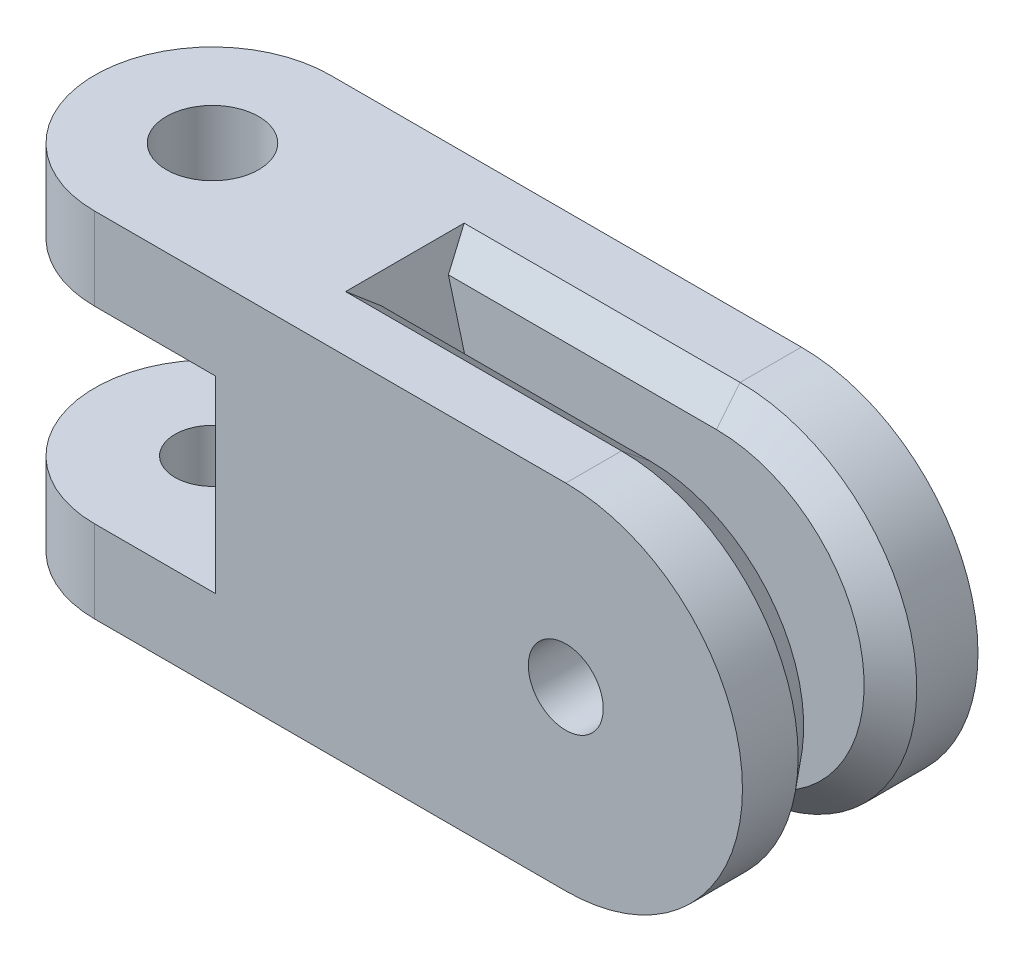
from build123d import *
from OCP.BRepFilletAPI import BRepFilletAPI_MakeChamfer

# Parameters (mm, degrees)
BOSS_EXTRUDE1_DEPTH        = 9.525
BOSS_EXTRUDE2_DEPTH        = 12.7
CUT_EXTRUDE1_DEPTH         = 5.08
F_10_32_TAPPED_HOLE1_D     = 4.0386
F_10_32_TAPPED_HOLE1_DEPTH = 4.445
F_10_CLEARANCE_HOLE1_D     = 4.9784
F_10_CLEARANCE_HOLE1_DEPTH = 14.604
CUT_EXTRUDE2_DEPTH         = 1.778
F_10_CLEARANCE_HOLE2_D     = 4.9784
F_10_CLEARANCE_HOLE2_DEPTH = 8.127
F_10_32_TAPPED_HOLE2_D     = 4.0386
CHAMFER1_SIZE              = 1.27
CHAMFER1_SIZE2             = 1.568319389


with BuildPart() as part:
    # Sketch1 → Boss-Extrude1 (new, symmetric)
    with BuildSketch(Plane(origin=(0, 0, 0), x_dir=(1, 0, 0), z_dir=(0, 1, 0))):
        with BuildLine():
            Line((0, -6.35), (-19.05, -6.35))
            ThreePointArc((-19.05, -6.35), (-25.4, 0), (-19.05, 6.35))
            Line((-19.05, 6.35), (0, 6.35))
            Line((0, 6.35), (0, -6.35))
        make_face()
    extrude(amount=BOSS_EXTRUDE1_DEPTH, both=True)

    # Sketch2 → Boss-Extrude2 (add)
    with BuildSketch(Plane.XY.offset(6.35)):
        with BuildLine():
            Line((0, 9.525), (6.35, 9.525))
            ThreePointArc((6.35, 9.525), (15.875, 0), (6.35, -9.525))
            Line((6.35, -9.525), (0, -9.525))
            ThreePointArc((0, -9.525), (-9.525, 0), (0, 9.525))
        make_face()
    extrude(amount=-BOSS_EXTRUDE2_DEPTH)

    # Sketch3 → Cut-Extrude1 (cut, symmetric)
    with BuildSketch(Plane(origin=(0, 0, 0), x_dir=(1, 0, 0), z_dir=(0, 1, 0))):
        with BuildLine():
            Line((-12.526499966, 6.35), (-19.05, 6.35))
            ThreePointArc((-19.05, 6.35), (-25.4, 0), (-19.05, -6.35))
            Line((-19.05, -6.35), (-12.526499966, -6.35))
            Line((-12.526499966, -6.35), (-12.526499966, 6.35))
        make_face()
    extrude(amount=CUT_EXTRUDE1_DEPTH, both=True, mode=Mode.SUBTRACT)

    # #10-32 Tapped Hole1
    with Locations(Plane(origin=(0, -5.08, 0), x_dir=(1, 0, 0), z_dir=(0, 1, 0))):
        with Locations((-19.05, 0)):
            Hole(F_10_32_TAPPED_HOLE1_D / 2, depth=F_10_32_TAPPED_HOLE1_DEPTH)

    # #10 Clearance Hole1
    with Locations(Plane(origin=(0, 9.525, 0), x_dir=(1, 0, 0), z_dir=(0, 1, 0))):
        with Locations((-19.05, 0)):
            Hole(F_10_CLEARANCE_HOLE1_D / 2, depth=F_10_CLEARANCE_HOLE1_DEPTH)

    # Sketch9 → Cut-Extrude2 (cut, symmetric)
    with BuildSketch(Plane.XY):
        with BuildLine():
            Line((-5.976257023, 0), (-8.528473081, -9.525))
            Line((-8.528473081, -9.525), (6.35, -9.525))
            ThreePointArc((6.35, -9.525), (15.875, 0), (6.35, 9.525))
            Line((6.35, 9.525), (-8.528473081, 9.525))
            Line((-8.528473081, 9.525), (-5.976257023, 0))
        make_face()
    extrude(amount=CUT_EXTRUDE2_DEPTH, both=True, mode=Mode.SUBTRACT)

    # #10 Clearance Hole2
    with Locations(Plane(origin=(0, 0, -6.35), x_dir=(-1, 0, 0), z_dir=(0, 0, -1))):
        with Locations((-6.35, 0)):
            Hole(F_10_CLEARANCE_HOLE2_D / 2, depth=F_10_CLEARANCE_HOLE2_DEPTH)

    # #10-32 Tapped Hole2 (through all)
    with Locations(Plane(origin=(0, 0, 1.778), x_dir=(-1, 0, 0), z_dir=(0, 0, -1))):
        with Locations((-6.35, 0)):
            Hole(F_10_32_TAPPED_HOLE2_D / 2)

    # Chamfer1: one chamfer whose edges measure the first distance from different faces: ONE call of the kernel's chamfer builder (chamfer() names one face for all edges)
    chamfer1_edges_1 = [part.edges().sort_by_distance(p)[0] for p in [
        (-1.08923654, -9.525, -1.778),
    ]]
    chamfer1_side_1 = [part.faces().sort_by_distance(p)[0] for p in [
        (-9.756442015, -9.525, 0),
    ]]
    chamfer1_edges_2 = [part.edges().sort_by_distance(p)[0] for p in [
        (15.875, 0, -1.778),
    ]]
    chamfer1_side_2 = [part.faces().sort_by_distance(p)[0] for p in [
        (15.875, 0, -4.064),
    ]]
    chamfer1_edges_3 = [part.edges().sort_by_distance(p)[0] for p in [
        (-1.08923654, 9.525, -1.778),
    ]]
    chamfer1_side_3 = [part.faces().sort_by_distance(p)[0] for p in [
        (-9.559168107, 9.525, 0),
    ]]
    chamfer1_edges_4 = [part.edges().sort_by_distance(p)[0] for p in [
        (-1.08923654, -9.525, 1.778),
        (15.875, 0, 1.778),
        (-1.08923654, 9.525, 1.778),
    ]]
    chamfer1_side_4 = [part.faces().sort_by_distance(p)[0] for p in [
        (3.285858214, 0, 1.778),
    ]]
    chamfer1 = BRepFilletAPI_MakeChamfer(part.part.solid().wrapped)
    for e in chamfer1_edges_1:
        chamfer1.Add(CHAMFER1_SIZE, CHAMFER1_SIZE2, e.wrapped, chamfer1_side_1[0].wrapped)  # the first distance lies on this face
    for e in chamfer1_edges_2:
        chamfer1.Add(CHAMFER1_SIZE, CHAMFER1_SIZE2, e.wrapped, chamfer1_side_2[0].wrapped)  # the first distance lies on this face
    for e in chamfer1_edges_3:
        chamfer1.Add(CHAMFER1_SIZE, CHAMFER1_SIZE2, e.wrapped, chamfer1_side_3[0].wrapped)  # the first distance lies on this face
    for e in chamfer1_edges_4:
        chamfer1.Add(CHAMFER1_SIZE, CHAMFER1_SIZE2, e.wrapped, chamfer1_side_4[0].wrapped)  # the first distance lies on this face
    add(Compound.cast(chamfer1.Shape()), mode=Mode.REPLACE)


solid = part.part
